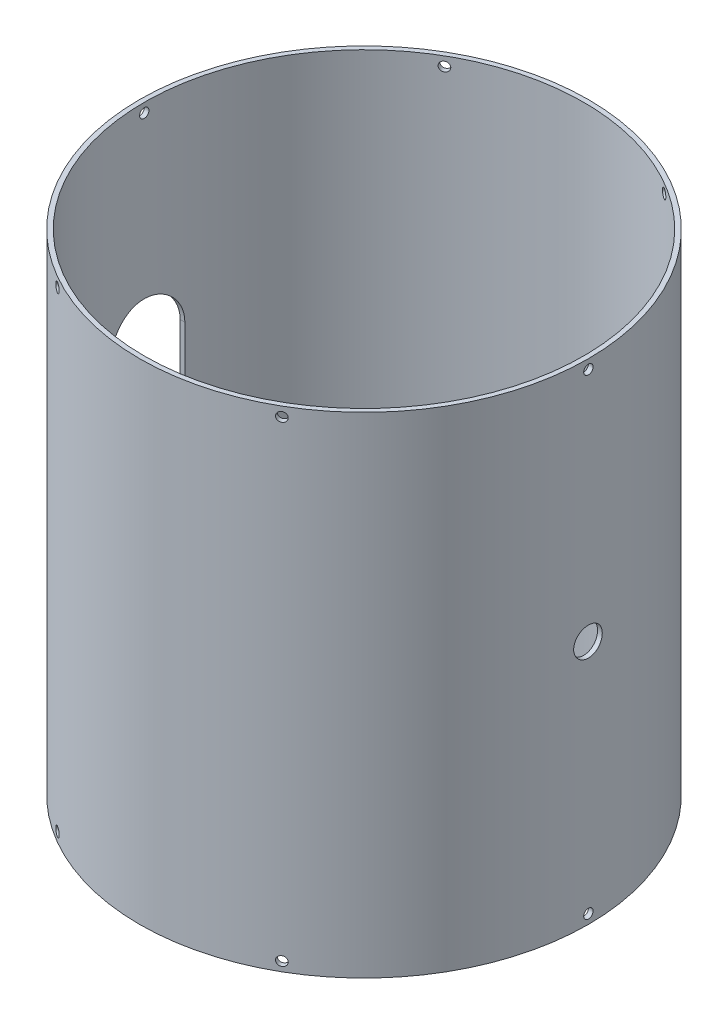
from build123d import *

# Parameters (mm, degrees)
SKETCH1_R           = 152.4
SKETCH1_R_2         = 149.225
BOSS_EXTRUDE1_DEPTH = 332.74
CUT_EXTRUDE1_DEPTH  = 190.5
SKETCH3_R           = 9.7155
CUT_EXTRUDE2_DEPTH  = 190.5
CUT_EXTRUDE3_START  = -305.8000001
SKETCH4_R           = 3.175
CUT_EXTRUDE3_DEPTH  = 306.8000002
CIRPATTERN1_COUNT   = 3


with BuildPart() as part:
    # Sketch1 → Boss-Extrude1 (new body)
    with BuildSketch(Plane(origin=(0, 0, 0), x_dir=(1, 0, 0), z_dir=(0, 1, 0))):
        Circle(SKETCH1_R)
        Circle(SKETCH1_R_2, mode=Mode.SUBTRACT)
    extrude(amount=BOSS_EXTRUDE1_DEPTH)

    # Sketch2 → Cut-Extrude1 (cut)
    with BuildSketch(Plane.ZY.offset(152.4)):
        with BuildLine():
            Line((25.4, 191.77), (25.4, 140.97))
            ThreePointArc((25.4, 140.97), (0, 115.57), (-25.4, 140.97))
            Line((-25.4, 140.97), (-25.4, 191.77))
            ThreePointArc((-25.4, 191.77), (0, 217.17), (25.4, 191.77))
        make_face()
    extrude(amount=-CUT_EXTRUDE1_DEPTH, mode=Mode.SUBTRACT)

    # Sketch3 → Cut-Extrude2 (cut)
    with BuildSketch(Plane(origin=(152.4, 0, 0), x_dir=(0, 0, -1), z_dir=(1, 0, 0))):
        with Locations((0, 166.37)):
            Circle(SKETCH3_R)
    extrude(amount=-CUT_EXTRUDE2_DEPTH, mode=Mode.SUBTRACT)

    # Sketch4 → Cut-Extrude3 (cut)
    with BuildSketch(Plane(origin=(152.4, 0, 0), x_dir=(0, 0, -1), z_dir=(1, 0, 0)).offset(CUT_EXTRUDE3_START)):
        with Locations((0, 6.35)):
            Circle(SKETCH4_R)
        with Locations((0, 326.39)):
            Circle(SKETCH4_R)
    cut_extrude3 = extrude(amount=CUT_EXTRUDE3_DEPTH, mode=Mode.SUBTRACT)

    # CirPattern1: Cut-Extrude3 ×3 about axis
    cirpattern1_axis = Axis((0, 332.74, 0), (0, -1, 0))
    for i in range(1, CIRPATTERN1_COUNT):
        add(cut_extrude3.rotate(cirpattern1_axis, i * 360 / CIRPATTERN1_COUNT), mode=Mode.SUBTRACT)


solid = part.part
